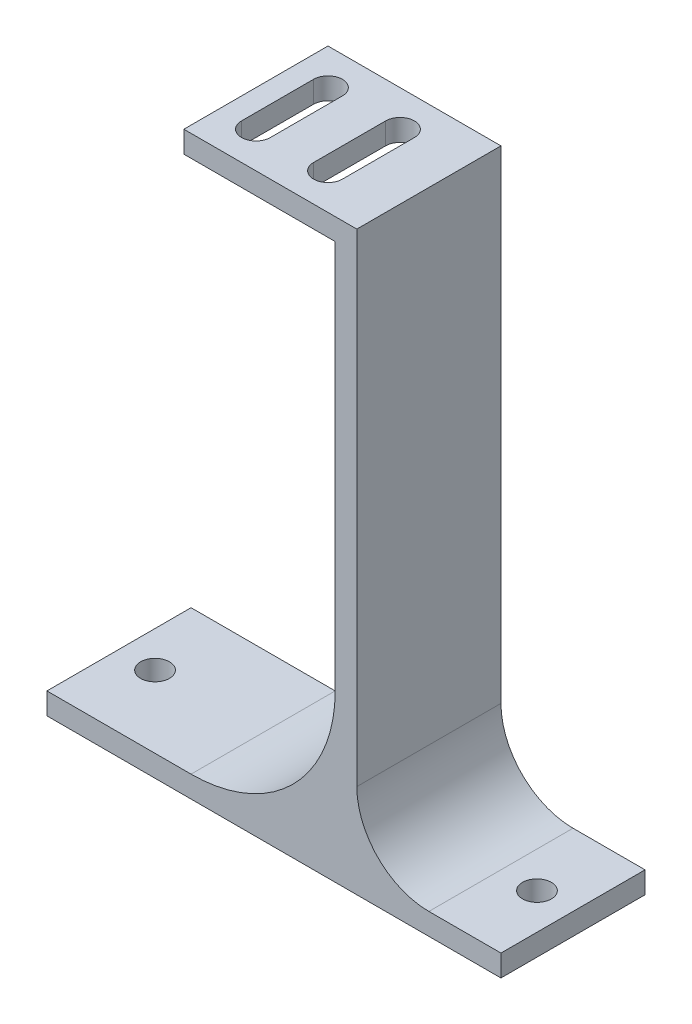
from build123d import *

# Parameters (mm, degrees)
BOSS_EXTRU_1_DEPTH      = 20
ENL_V_MAT_EXTRU_1_DEPTH = 3
CONG_1_R                = 20
CONG_2_R                = 10
ESQUISSE3_R             = 2
ENL_V_MAT_EXTRU_2_DEPTH = 3


with BuildPart() as part:
    # Esquisse1 → Boss.-Extru.1 (new body)
    with BuildSketch(Plane.XY):
        Polygon((43, 3), (63, 3), (63, 0), (0, 0), (0, 3), (40, 3), (40, 77), (19, 77), (19, 80), (43, 80), align=None)
    extrude(amount=BOSS_EXTRU_1_DEPTH)

    # Esquisse2 → Enlèv. mat.-Extru.1 (cut)
    with BuildSketch(Plane(origin=(0, 80, 0), x_dir=(1, 0, 0), z_dir=(0, 1, 0))):
        with BuildLine():
            Line((26, -5), (26, -15))
            ThreePointArc((26, -15), (24, -17), (22, -15))
            Line((22, -15), (22, -5))
            ThreePointArc((22, -5), (24, -3), (26, -5))
        make_face()
        with BuildLine():
            Line((36, -5), (36, -15))
            ThreePointArc((36, -15), (34, -17), (32, -15))
            Line((32, -15), (32, -5))
            ThreePointArc((32, -5), (34, -3), (36, -5))
        make_face()
    extrude(amount=-ENL_V_MAT_EXTRU_1_DEPTH, mode=Mode.SUBTRACT)

    # Congé1
    cong_1_edges = [part.edges().sort_by_distance(p)[0] for p in [
        (40, 3, 10),
    ]]
    fillet(cong_1_edges, radius=CONG_1_R)

    # Congé2
    cong_2_edges = [part.edges().sort_by_distance(p)[0] for p in [
        (43, 3, 10),
    ]]
    fillet(cong_2_edges, radius=CONG_2_R)

    # Esquisse3 → Enlèv. mat.-Extru.2 (cut)
    with BuildSketch(Plane(origin=(0, 3, 0), x_dir=(1, 0, 0), z_dir=(0, 1, 0))):
        with Locations((5, -10)):
            Circle(ESQUISSE3_R)
        with Locations((58, -10)):
            Circle(ESQUISSE3_R)
    extrude(amount=-ENL_V_MAT_EXTRU_2_DEPTH, mode=Mode.SUBTRACT)


solid = part.part
